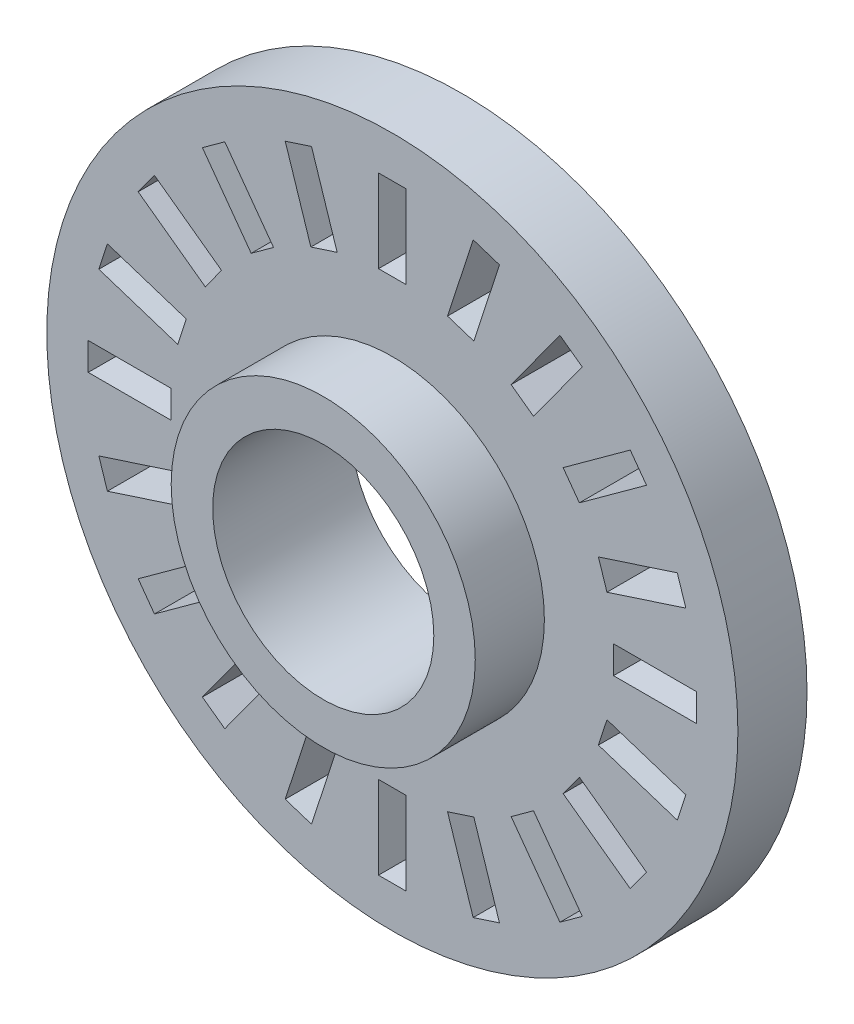
from build123d import *

# Parameters (mm, degrees)
SKETCH_1_R               = 25
SKETCH_1_R_2             = 8
EXTRUDE_1_DEPTH          = 5
SKETCH_2_R               = 11
SKETCH_2_R_2             = 8
EXTRUDE_2_DEPTH          = 5
SKETCH_3_W               = 2
SKETCH_3_H               = 6
CUT_EXTRUDE_1_DEPTH      = 5
PATTERN_CIRCULAR_1_COUNT = 20


with BuildPart() as part:
    # 草图1 → 凸台-拉伸1 (new body)
    with BuildSketch(Plane.XY):
        Circle(SKETCH_1_R)
        Circle(SKETCH_1_R_2, mode=Mode.SUBTRACT)
    extrude(amount=EXTRUDE_1_DEPTH)

    # 草图2 → 凸台-拉伸2 (add)
    with BuildSketch(Plane.XY.offset(5)):
        Circle(SKETCH_2_R)
        Circle(SKETCH_2_R_2, mode=Mode.SUBTRACT)
    extrude(amount=EXTRUDE_2_DEPTH)

    # 草图3 → 切除-拉伸1 (cut)
    with BuildSketch(Plane.XY.offset(5)):
        with Locations((0, 19)):
            Rectangle(SKETCH_3_W, SKETCH_3_H)
    cut_extrude_1 = extrude(amount=-CUT_EXTRUDE_1_DEPTH, mode=Mode.SUBTRACT)

    # 阵列(圆周)1: 切除-拉伸1 ×20 about axis
    pattern_circular_1_axis = Axis((0, 0, 0), (0, 0, 1))
    for i in range(1, PATTERN_CIRCULAR_1_COUNT):
        add(cut_extrude_1.rotate(pattern_circular_1_axis, i * 360 / PATTERN_CIRCULAR_1_COUNT), mode=Mode.SUBTRACT)


solid = part.part
